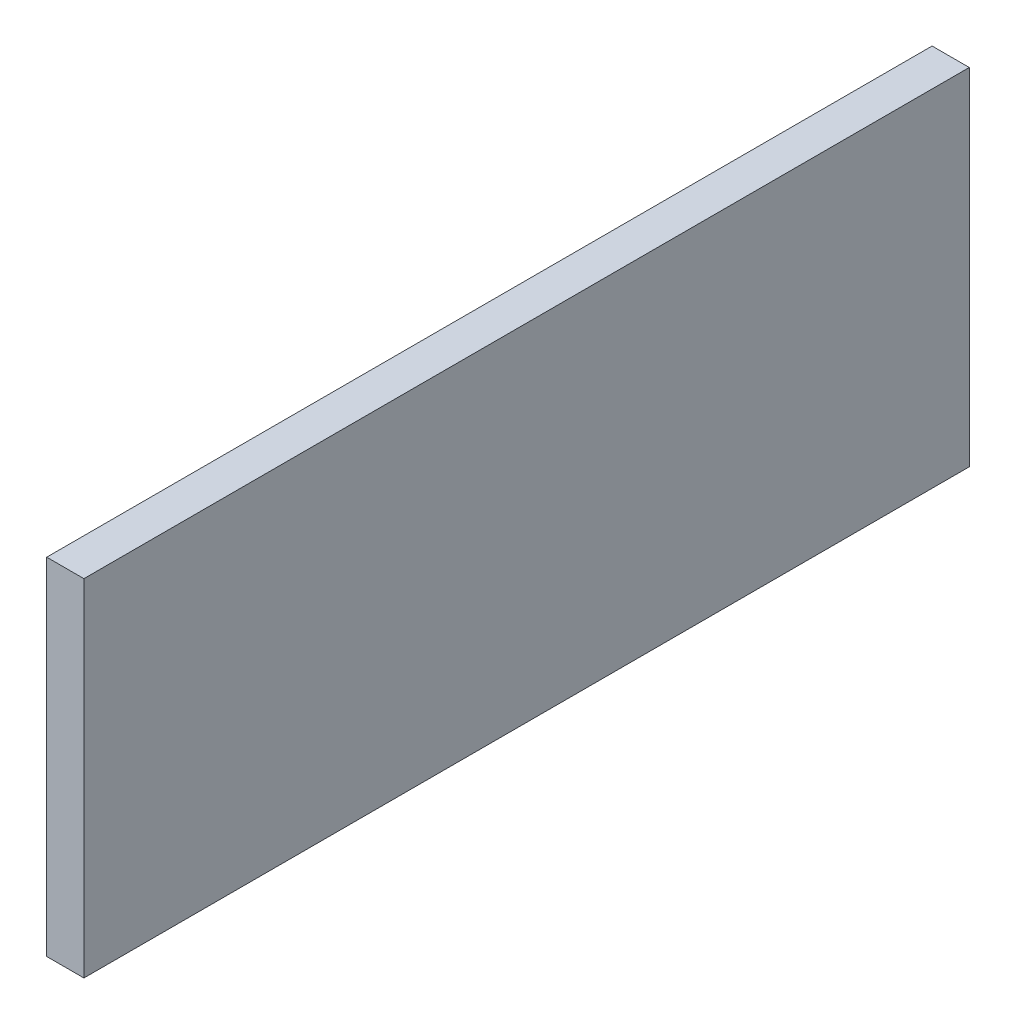
from build123d import *

# Parameters (mm, degrees)
SKETCH1_W           = 3.175
SKETCH1_H           = 29.52
BOSS_EXTRUDE1_DEPTH = 75.57


with BuildPart() as part:
    # Sketch1 → Boss-Extrude1 (new body)
    with BuildSketch(Plane.XY):
        Rectangle(SKETCH1_W, SKETCH1_H)
    extrude(amount=BOSS_EXTRUDE1_DEPTH)


solid = part.part
